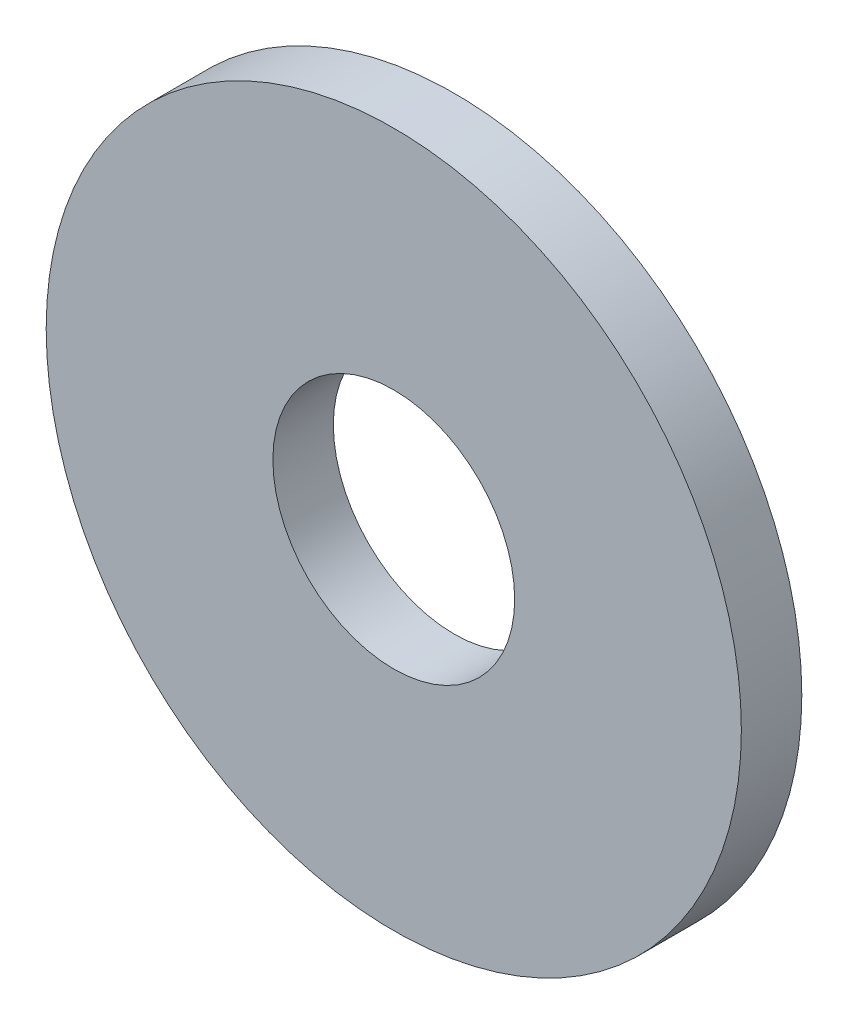
from build123d import *

# Parameters (mm, degrees)
SKETCH1_R           = 11.5
SKETCH1_R_2         = 4
BOSS_EXTRUDE1_DEPTH = 2


with BuildPart() as part:
    # Sketch1 → Boss-Extrude1 (new body)
    with BuildSketch(Plane.XY):
        Circle(SKETCH1_R)
        Circle(SKETCH1_R_2, mode=Mode.SUBTRACT)
    extrude(amount=BOSS_EXTRUDE1_DEPTH)


solid = part.part
